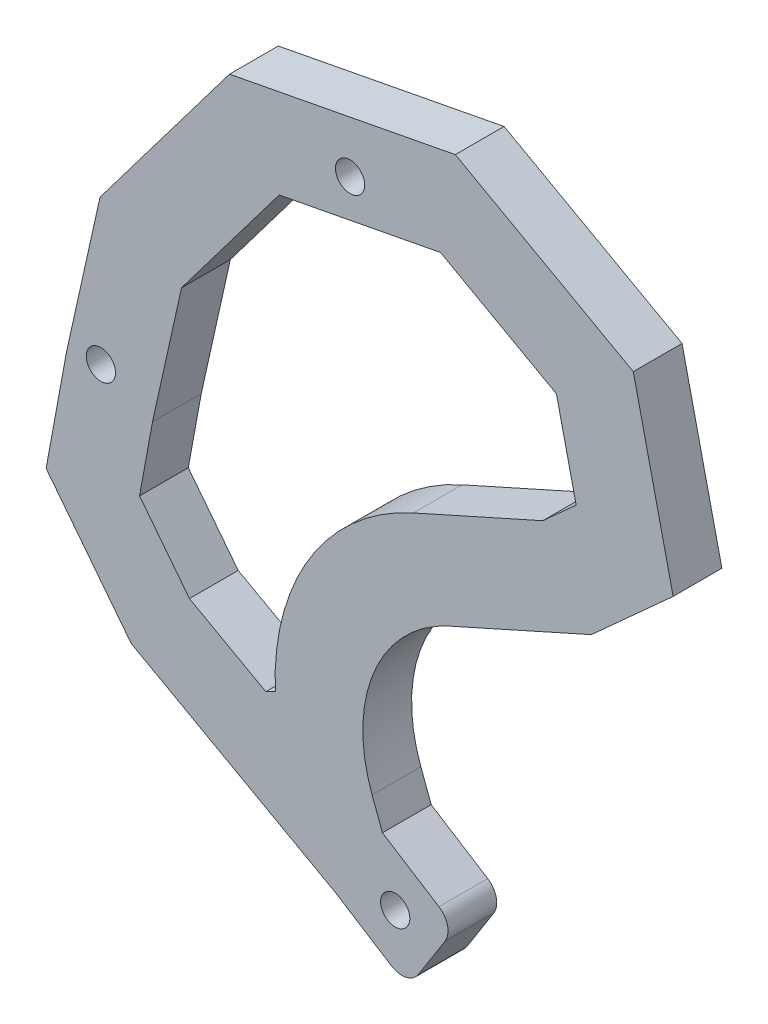
from build123d import *

# Parameters (mm, degrees)
SKETCH2_R           = 1.5
BOSS_EXTRUDE1_DEPTH = 5
FILLET1_R           = 2


with BuildPart() as part:
    # Sketch2 → Boss-Extrude1 (new body)
    with BuildSketch(Plane(origin=(6.301928067, 33.341579781, -27), x_dir=(-0.670801619, 0.74163683, 0), z_dir=(0, 0, -1))):
        with BuildLine():
            Line((-60.01425581, -23.839998272), (-68.549452032, -21.468875235))
            Line((-68.549452032, -21.468875235), (-70.98574419, -30.238657023))
            Line((-70.98574419, -30.238657023), (-62.450547968, -32.60978006))
            Line((-62.450547968, -32.60978006), (-39.815769516, -40.315756269))
            Line((-39.815769516, -40.315756269), (-25.661547731, -39.280246834))
            Line((-25.661547731, -39.280246834), (-18.621605657, -30.094798604))
            Line((-18.621605657, -30.094798604), (-9.456704001, -17.167000829))
            Line((-9.456704001, -17.167000829), (-5.335690467, 4.468320227))
            Line((-5.335690467, 4.468320227), (-17.584258472, 24.615497506))
            Line((-17.584258472, 24.615497506), (-22.792310688, 26.388571034))
            Line((-22.792310688, 26.388571034), (-37.355145596, 31.346466229))
            Line((-37.355145596, 31.346466229), (-53.38998859, 22.351505712))
            Line((-53.38998859, 22.351505712), (-53.38998859, 11.040844476))
            Line((-53.38998859, 11.040844476), (-48.457282179, -4.144818068))
            ThreePointArc((-48.457282179, -4.144818068), (-49.150509534, -15.1642744), (-57.197834388, -22.724006186))
            Line((-57.197834388, -22.724006186), (-60.01425581, -23.839998272))
        make_face()
        with Locations((-65.5, -27.039327647)):
            Circle(SKETCH2_R, mode=Mode.SUBTRACT)
        with Locations((-20.5, -27.039327647)):
            Circle(SKETCH2_R, mode=Mode.SUBTRACT)
        with Locations((-15.8, 11.676431418)):
            Circle(SKETCH2_R, mode=Mode.SUBTRACT)
        with BuildLine():
            Line((-47.130315082, -28.318253081), (-38.647453771, -31.206230429))
            Line((-38.647453771, -31.206230429), (-30.347341702, -30.599002106))
            Line((-30.347341702, -30.599002106), (-25.866841879, -24.753016622))
            Line((-25.866841879, -24.753016622), (-17.931352522, -13.559399331))
            Line((-17.931352522, -13.559399331), (-14.824551002, 2.751308649))
            Line((-14.824551002, 2.751308649), (-23.577444554, 17.1485915))
            Line((-23.577444554, 17.1485915), (-25.692860174, 17.86878156))
            Line((-25.692860174, 17.86878156), (-36.454250771, 21.532480769))
            Line((-36.454250771, 21.532480769), (-44.38998859, 17.080822067))
            Line((-44.38998859, 17.080822067), (-44.38998859, 12.465915799))
            Line((-44.38998859, 12.465915799), (-39.897539246, -1.364386282))
            ThreePointArc((-39.897539246, -1.364386282), (-39.671812155, -15.458597607), (-47.39803378, -27.248561347))
            Line((-47.39803378, -27.248561347), (-47.130315082, -28.318253081))
        make_face(mode=Mode.SUBTRACT)
    extrude(amount=-BOSS_EXTRUDE1_DEPTH)

    # Fillet1
    fillet1_edges = [part.edges().sort_by_distance(p)[0] for p in [
        (31.493178432, -39.588202626, -24.5),
        (36.362902877, -31.898574812, -24.5),
    ]]
    fillet(fillet1_edges, radius=FILLET1_R)


solid = part.part
